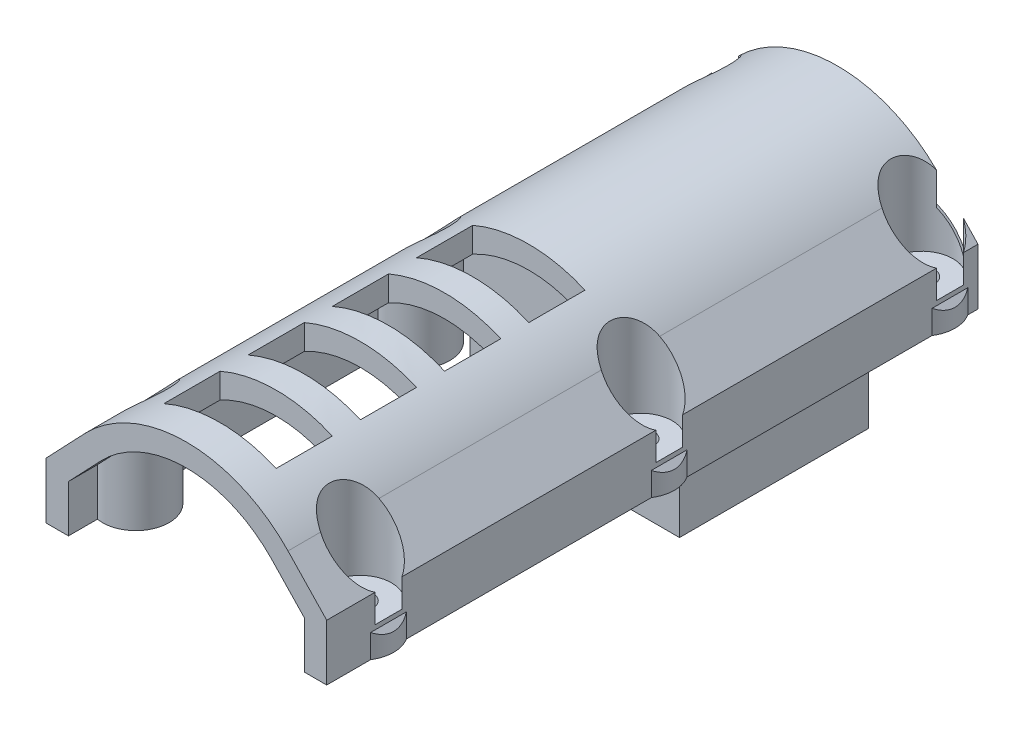
from build123d import *

# Parameters (mm, degrees)
BOSS_EXTRUDE1_DEPTH  = 116
SHELL1_T             = -4
BOSS_EXTRUDE2_REACH  = 27
SKETCH4_R            = 5.925
BOSS_EXTRUDE3_REACH  = 27
SKETCH4_3_R          = 5.925
CUT_EXTRUDE1_REACH   = 27
SKETCH5_R            = 2.25
SKETCH6_R            = 5.54
CUT_EXTRUDE2_DEPTH   = 20
CUT_EXTRUDE3_REACH   = 27
SKETCH7_W            = 20
SKETCH7_H            = 10
BOSS_EXTRUDE14_DEPTH = 13
BOSS_EXTRUDE15_DEPTH = 15
SKETCH11_W           = 12
SKETCH11_H           = 32
CUT_EXTRUDE5_DEPTH   = 1
SKETCH12_W           = 12
SKETCH12_H           = 22
CUT_EXTRUDE6_DEPTH   = 18
SKETCH13_R           = 1
CUT_EXTRUDE7_DEPTH   = 15
SKETCH14_R           = 0.5
CUT_EXTRUDE8_DEPTH   = 10


with BuildPart() as part:
    # Sketch1 → Boss-Extrude1 (new body)
    with BuildSketch(Plane.XY):
        with BuildLine():
            Line((-25, 0), (-25, 10))
            Line((-25, 10), (-18.103448276, 17.24137931))
            ThreePointArc((-18.103448276, 17.24137931), (0, 25), (18.103448276, 17.24137931))
            Line((18.103448276, 17.24137931), (25, 10))
            Line((25, 10), (25, 0))
            Line((25, 0), (-25, 0))
        make_face()
    extrude(amount=BOSS_EXTRUDE1_DEPTH)

    # Shell1
    shell1_openings = [part.faces().sort_by_distance(p)[0] for p in [
        (0, 10.373563218, 116),
        (0, 0, 58),
    ]]
    offset(amount=SHELL1_T, openings=shell1_openings, kind=Kind.INTERSECTION)

    # Boss-Extrude2: up to this face of the body (flat: up to its plane)
    boss_extrude2_end = Plane(part.part.faces().sort_by_distance((-18.103448276, 11.44137931, 60))[0])
    # Sketch4 → Boss-Extrude2 (add, up to the picked face)
    with BuildSketch(Plane.XZ, mode=Mode.PRIVATE) as boss_extrude2_sk1:
        with Locations((-20, 5)):
            Circle(SKETCH4_R)
    boss_extrude2_tool1 = split(extrude(boss_extrude2_sk1.sketch, amount=-BOSS_EXTRUDE2_REACH, mode=Mode.PRIVATE), bisect_by=boss_extrude2_end, keep=Keep.BOTH, mode=Mode.PRIVATE)
    add(boss_extrude2_tool1.solids().sort_by_distance((-20, 0, 5))[0])
    # Sketch4 → Boss-Extrude2 (add, up to the picked face)
    with BuildSketch(Plane.XZ, mode=Mode.PRIVATE) as boss_extrude2_sk2:
        with Locations((-20, 55)):
            Circle(SKETCH4_R)
    boss_extrude2_tool2 = split(extrude(boss_extrude2_sk2.sketch, amount=-BOSS_EXTRUDE2_REACH, mode=Mode.PRIVATE), bisect_by=boss_extrude2_end, keep=Keep.BOTH, mode=Mode.PRIVATE)
    add(boss_extrude2_tool2.solids().sort_by_distance((-20, 0, 55))[0])
    # Sketch4 → Boss-Extrude2 (add, up to the picked face)
    with BuildSketch(Plane.XZ, mode=Mode.PRIVATE) as boss_extrude2_sk3:
        with Locations((-20, 105)):
            Circle(SKETCH4_R)
    boss_extrude2_tool3 = split(extrude(boss_extrude2_sk3.sketch, amount=-BOSS_EXTRUDE2_REACH, mode=Mode.PRIVATE), bisect_by=boss_extrude2_end, keep=Keep.BOTH, mode=Mode.PRIVATE)
    add(boss_extrude2_tool3.solids().sort_by_distance((-20, 0, 105))[0])

    # Boss-Extrude3: up to this face of the body (flat: up to its plane)
    boss_extrude3_end = Plane(part.part.faces().sort_by_distance((18.103448276, 11.44137931, 60))[0])
    # Sketch4_3 → Boss-Extrude3 (add, up to the picked face)
    with BuildSketch(Plane.XZ, mode=Mode.PRIVATE) as boss_extrude3_sk1:
        with Locations((20, 105)):
            Circle(SKETCH4_3_R)
    boss_extrude3_tool1 = split(extrude(boss_extrude3_sk1.sketch, amount=-BOSS_EXTRUDE3_REACH, mode=Mode.PRIVATE), bisect_by=boss_extrude3_end, keep=Keep.BOTH, mode=Mode.PRIVATE)
    add(boss_extrude3_tool1.solids().sort_by_distance((20, 0, 105))[0])
    # Sketch4_3 → Boss-Extrude3 (add, up to the picked face)
    with BuildSketch(Plane.XZ, mode=Mode.PRIVATE) as boss_extrude3_sk2:
        with Locations((20, 55)):
            Circle(SKETCH4_3_R)
    boss_extrude3_tool2 = split(extrude(boss_extrude3_sk2.sketch, amount=-BOSS_EXTRUDE3_REACH, mode=Mode.PRIVATE), bisect_by=boss_extrude3_end, keep=Keep.BOTH, mode=Mode.PRIVATE)
    add(boss_extrude3_tool2.solids().sort_by_distance((20, 0, 55))[0])
    # Sketch4_3 → Boss-Extrude3 (add, up to the picked face)
    with BuildSketch(Plane.XZ, mode=Mode.PRIVATE) as boss_extrude3_sk3:
        with Locations((20, 5)):
            Circle(SKETCH4_3_R)
    boss_extrude3_tool3 = split(extrude(boss_extrude3_sk3.sketch, amount=-BOSS_EXTRUDE3_REACH, mode=Mode.PRIVATE), bisect_by=boss_extrude3_end, keep=Keep.BOTH, mode=Mode.PRIVATE)
    add(boss_extrude3_tool3.solids().sort_by_distance((20, 0, 5))[0])

    # Sketch5 → Cut-Extrude1 (cut, up to next)
    with BuildSketch(Plane.XZ, mode=Mode.PRIVATE) as cut_extrude1_sk1:
        with Locations((-20, 5)):
            Circle(SKETCH5_R)
    cut_extrude1_tool1 = extrude(cut_extrude1_sk1.sketch, amount=-CUT_EXTRUDE1_REACH, mode=Mode.PRIVATE) & part.part
    add(cut_extrude1_tool1.solids().sort_by_distance((-20, 0, 5))[0], mode=Mode.SUBTRACT)
    # Sketch5 → Cut-Extrude1 (cut, up to next)
    with BuildSketch(Plane.XZ, mode=Mode.PRIVATE) as cut_extrude1_sk2:
        with Locations((-20, 55)):
            Circle(SKETCH5_R)
    cut_extrude1_tool2 = extrude(cut_extrude1_sk2.sketch, amount=-CUT_EXTRUDE1_REACH, mode=Mode.PRIVATE) & part.part
    add(cut_extrude1_tool2.solids().sort_by_distance((-20, 0, 55))[0], mode=Mode.SUBTRACT)
    # Sketch5 → Cut-Extrude1 (cut, up to next)
    with BuildSketch(Plane.XZ, mode=Mode.PRIVATE) as cut_extrude1_sk3:
        with Locations((-20, 105)):
            Circle(SKETCH5_R)
    cut_extrude1_tool3 = extrude(cut_extrude1_sk3.sketch, amount=-CUT_EXTRUDE1_REACH, mode=Mode.PRIVATE) & part.part
    add(cut_extrude1_tool3.solids().sort_by_distance((-20, 0, 105))[0], mode=Mode.SUBTRACT)
    # Sketch5 → Cut-Extrude1 (cut, up to next)
    with BuildSketch(Plane.XZ, mode=Mode.PRIVATE) as cut_extrude1_sk4:
        with Locations((20, 105)):
            Circle(SKETCH5_R)
    cut_extrude1_tool4 = extrude(cut_extrude1_sk4.sketch, amount=-CUT_EXTRUDE1_REACH, mode=Mode.PRIVATE) & part.part
    add(cut_extrude1_tool4.solids().sort_by_distance((20, 0, 105))[0], mode=Mode.SUBTRACT)
    # Sketch5 → Cut-Extrude1 (cut, up to next)
    with BuildSketch(Plane.XZ, mode=Mode.PRIVATE) as cut_extrude1_sk5:
        with Locations((20, 55)):
            Circle(SKETCH5_R)
    cut_extrude1_tool5 = extrude(cut_extrude1_sk5.sketch, amount=-CUT_EXTRUDE1_REACH, mode=Mode.PRIVATE) & part.part
    add(cut_extrude1_tool5.solids().sort_by_distance((20, 0, 55))[0], mode=Mode.SUBTRACT)
    # Sketch5 → Cut-Extrude1 (cut, up to next)
    with BuildSketch(Plane.XZ, mode=Mode.PRIVATE) as cut_extrude1_sk6:
        with Locations((20, 5)):
            Circle(SKETCH5_R)
    cut_extrude1_tool6 = extrude(cut_extrude1_sk6.sketch, amount=-CUT_EXTRUDE1_REACH, mode=Mode.PRIVATE) & part.part
    add(cut_extrude1_tool6.solids().sort_by_distance((20, 0, 5))[0], mode=Mode.SUBTRACT)

    # Sketch6 → Cut-Extrude2 (cut)
    with BuildSketch(Plane(origin=(0, 25, 0), x_dir=(1, 0, 0), z_dir=(0, 1, 0))):
        with Locations((20, -105)):
            Circle(SKETCH6_R)
        with Locations((20, -55)):
            Circle(SKETCH6_R)
        with Locations((20, -5)):
            Circle(SKETCH6_R)
        with Locations((-20, -5)):
            Circle(SKETCH6_R)
        with Locations((-20, -55)):
            Circle(SKETCH6_R)
        with Locations((-20, -105)):
            Circle(SKETCH6_R)
    extrude(amount=-CUT_EXTRUDE2_DEPTH, mode=Mode.SUBTRACT)

    # Sketch7 → Cut-Extrude3 (cut, up to next)
    with BuildSketch(Plane(origin=(0, 25, 0), x_dir=(1, 0, 0), z_dir=(0, 1, 0)), mode=Mode.PRIVATE) as cut_extrude3_sk1:
        with Locations((0, -105)):
            Rectangle(SKETCH7_W, SKETCH7_H)
    cut_extrude3_tool1 = extrude(cut_extrude3_sk1.sketch, amount=-CUT_EXTRUDE3_REACH, mode=Mode.PRIVATE) & part.part
    add(cut_extrude3_tool1.solids().sort_by_distance((0, 25, 105))[0], mode=Mode.SUBTRACT)
    # Sketch7 → Cut-Extrude3 (cut, up to next)
    with BuildSketch(Plane(origin=(0, 25, 0), x_dir=(1, 0, 0), z_dir=(0, 1, 0)), mode=Mode.PRIVATE) as cut_extrude3_sk2:
        with Locations((0, -90)):
            Rectangle(SKETCH7_W, SKETCH7_H)
    cut_extrude3_tool2 = extrude(cut_extrude3_sk2.sketch, amount=-CUT_EXTRUDE3_REACH, mode=Mode.PRIVATE) & part.part
    add(cut_extrude3_tool2.solids().sort_by_distance((0, 25, 90))[0], mode=Mode.SUBTRACT)
    # Sketch7 → Cut-Extrude3 (cut, up to next)
    with BuildSketch(Plane(origin=(0, 25, 0), x_dir=(1, 0, 0), z_dir=(0, 1, 0)), mode=Mode.PRIVATE) as cut_extrude3_sk3:
        with Locations((0, -75)):
            Rectangle(SKETCH7_W, SKETCH7_H)
    cut_extrude3_tool3 = extrude(cut_extrude3_sk3.sketch, amount=-CUT_EXTRUDE3_REACH, mode=Mode.PRIVATE) & part.part
    add(cut_extrude3_tool3.solids().sort_by_distance((0, 25, 75))[0], mode=Mode.SUBTRACT)
    # Sketch7 → Cut-Extrude3 (cut, up to next)
    with BuildSketch(Plane(origin=(0, 25, 0), x_dir=(1, 0, 0), z_dir=(0, 1, 0)), mode=Mode.PRIVATE) as cut_extrude3_sk4:
        with Locations((0, -60)):
            Rectangle(SKETCH7_W, SKETCH7_H)
    cut_extrude3_tool4 = extrude(cut_extrude3_sk4.sketch, amount=-CUT_EXTRUDE3_REACH, mode=Mode.PRIVATE) & part.part
    add(cut_extrude3_tool4.solids().sort_by_distance((0, 25, 60))[0], mode=Mode.SUBTRACT)

    # Sketch8 → Boss-Extrude14 (add)
    with BuildSketch(Plane.XZ):
        with BuildLine():
            Line((21, 10.84000214), (21, 46.84000214))
            Line((21, 46.84000214), (-21, 46.84000214))
            Line((-21, 46.84000214), (-21, 10.84000214))
            ThreePointArc((-21, 10.84000214), (-15.810392321, 9.189607679), (-14.15999786, 4))
            Line((-14.15999786, 4), (14.15999786, 4))
            ThreePointArc((14.15999786, 4), (15.810392321, 9.189607679), (21, 10.84000214))
        make_face()
    extrude(amount=-BOSS_EXTRUDE14_DEPTH)

    # Sketch10 → Boss-Extrude15 (add)
    with BuildSketch(Plane.XZ):
        with BuildLine():
            Line((18.67, 46.83499309), (18.67, 13.151209188))
            ThreePointArc((18.67, 13.151209188), (14.195270877, 10.875054875), (11.865391063, 6.428062719))
            Line((11.865391063, 6.428062719), (-11.865391063, 6.428062719))
            ThreePointArc((-11.865391063, 6.428062719), (-14.195270877, 10.875054875), (-18.67, 13.151209188))
            Line((-18.67, 13.151209188), (-18.67, 46.83499309))
            Line((-18.67, 46.83499309), (18.67, 46.83499309))
        make_face()
    extrude(amount=BOSS_EXTRUDE15_DEPTH)

    # Sketch11 → Cut-Extrude5 (cut)
    with BuildSketch(Plane.XZ.offset(15)):
        with Locations((-1, 22.428062719)):
            Rectangle(SKETCH11_W, SKETCH11_H)
    extrude(amount=-CUT_EXTRUDE5_DEPTH, mode=Mode.SUBTRACT)

    # Sketch12 → Cut-Extrude6 (cut)
    with BuildSketch(Plane.XZ.offset(14)):
        with Locations((-1, 22.428062719)):
            Rectangle(SKETCH12_W, SKETCH12_H)
    extrude(amount=-CUT_EXTRUDE6_DEPTH, mode=Mode.SUBTRACT)

    # Sketch13 → Cut-Extrude7 (cut)
    with BuildSketch(Plane.XZ.offset(14)):
        with Locations((-1, 8.528062719)):
            Circle(SKETCH13_R)
        with Locations((-1, 36.328062719)):
            Circle(SKETCH13_R)
    extrude(amount=-CUT_EXTRUDE7_DEPTH, mode=Mode.SUBTRACT)

    # Sketch14 → Cut-Extrude8 (cut)
    with BuildSketch(Plane.XZ):
        with Locations((-23, 10)):
            Circle(SKETCH14_R)
        with Locations((-23, 25)):
            Circle(SKETCH14_R)
        with Locations((23, 25)):
            Circle(SKETCH14_R)
        with Locations((23, 10)):
            Circle(SKETCH14_R)
    extrude(amount=-CUT_EXTRUDE8_DEPTH, mode=Mode.SUBTRACT)


solid = part.part
